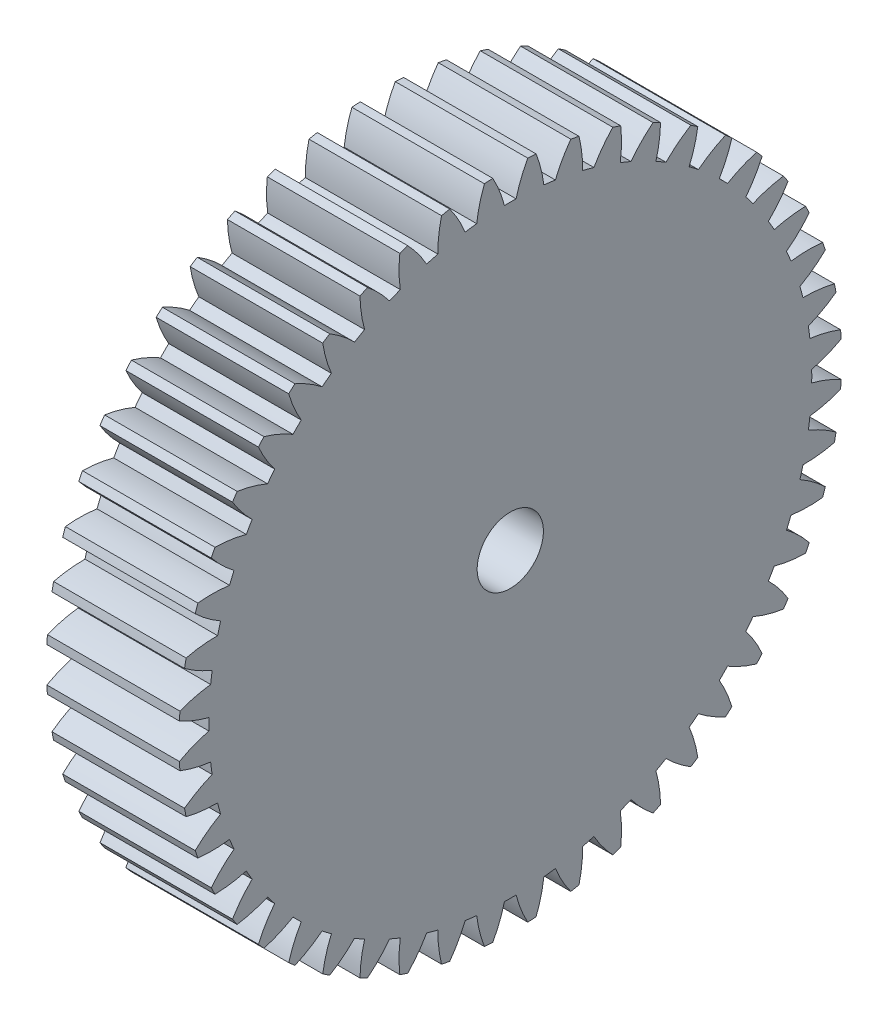
from build123d import *

# Parameters (mm, degrees)
BASPROSKE_W     = 10
BASPROSKE_H     = 25
TOOTHCUT_DEPTH  = 37.742346142
TEETHCUTS_COUNT = 48
TEETHCUTS_ANGLE = 352.5
BORSKE_R        = 2.5
BORE_DEPTH      = 50.0000508


with BuildPart() as part:
    # BasProSke → Base-Revolve (revolve)
    with BuildSketch(Plane(origin=(0, 0, 0), x_dir=(1, 0, 0), z_dir=(0, 1, 0)), mode=Mode.PRIVATE) as base_revolve_sk:
        with Locations((5, 12.5)):
            Rectangle(BASPROSKE_W, BASPROSKE_H)
    revolve(base_revolve_sk.sketch.rotate(Axis((-10, 0, 0), (1, 0, 0)), 180), axis=Axis((-10, 0, 0), (1, 0, 0)))

    # TooCutSke → ToothCut (cut, through all)
    with BuildSketch(Plane(origin=(0, 0, 0), x_dir=(0, 0, -1), z_dir=(1, 0, 0))):
        with BuildLine():
            ThreePointArc((0.439519311, 22.744753764), (0, 22.749), (-0.439519311, 22.744753764))
            ThreePointArc((-0.439519311, 22.744753764), (-0.815652087, 23.895542925), (-1.33363602, 24.989839138))
            ThreePointArc((-1.33363602, 24.989839138), (0, 25.0254), (1.33363602, 24.989839138))
            ThreePointArc((1.33363602, 24.989839138), (0.815652087, 23.895542925), (0.439519311, 22.744753764))
        make_face()
    toothcut = extrude(amount=TOOTHCUT_DEPTH, mode=Mode.SUBTRACT)

    # TeethCuts: ToothCut ×48 about axis
    teethcuts_axis = Axis((-10, 0, 0), (1, 0, 0))
    for i in range(1, TEETHCUTS_COUNT):
        add(toothcut.rotate(teethcuts_axis, i * TEETHCUTS_ANGLE / (TEETHCUTS_COUNT - 1)), mode=Mode.SUBTRACT)

    # BorSke → Bore (cut, symmetric)
    with BuildSketch(Plane(origin=(0, 0, 0), x_dir=(0, 0, -1), z_dir=(1, 0, 0))):
        with Locations(Location((0, 0, 0), (0, 0, 180))):
            Circle(BORSKE_R)
    extrude(amount=BORE_DEPTH, both=True, mode=Mode.SUBTRACT)


solid = part.part
